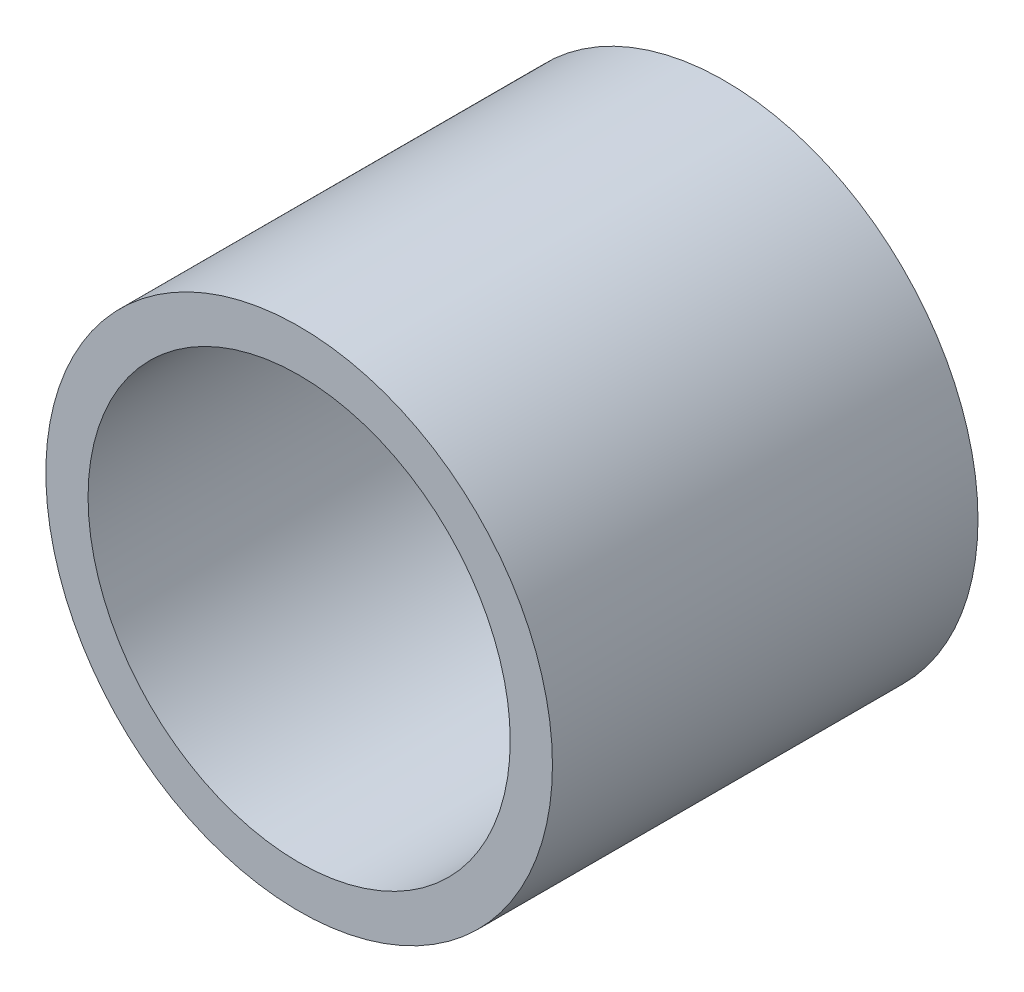
from build123d import *

# Parameters (mm, degrees)
SKETCH1_R           = 9.525
SKETCH1_R_2         = 7.9375
BOSS_EXTRUDE1_DEPTH = 8.001


with BuildPart() as part:
    # Sketch1 → Boss-Extrude1 (new body, symmetric)
    with BuildSketch(Plane.XY):
        Circle(SKETCH1_R)
        Circle(SKETCH1_R_2, mode=Mode.SUBTRACT)
    extrude(amount=BOSS_EXTRUDE1_DEPTH, both=True)


solid = part.part
